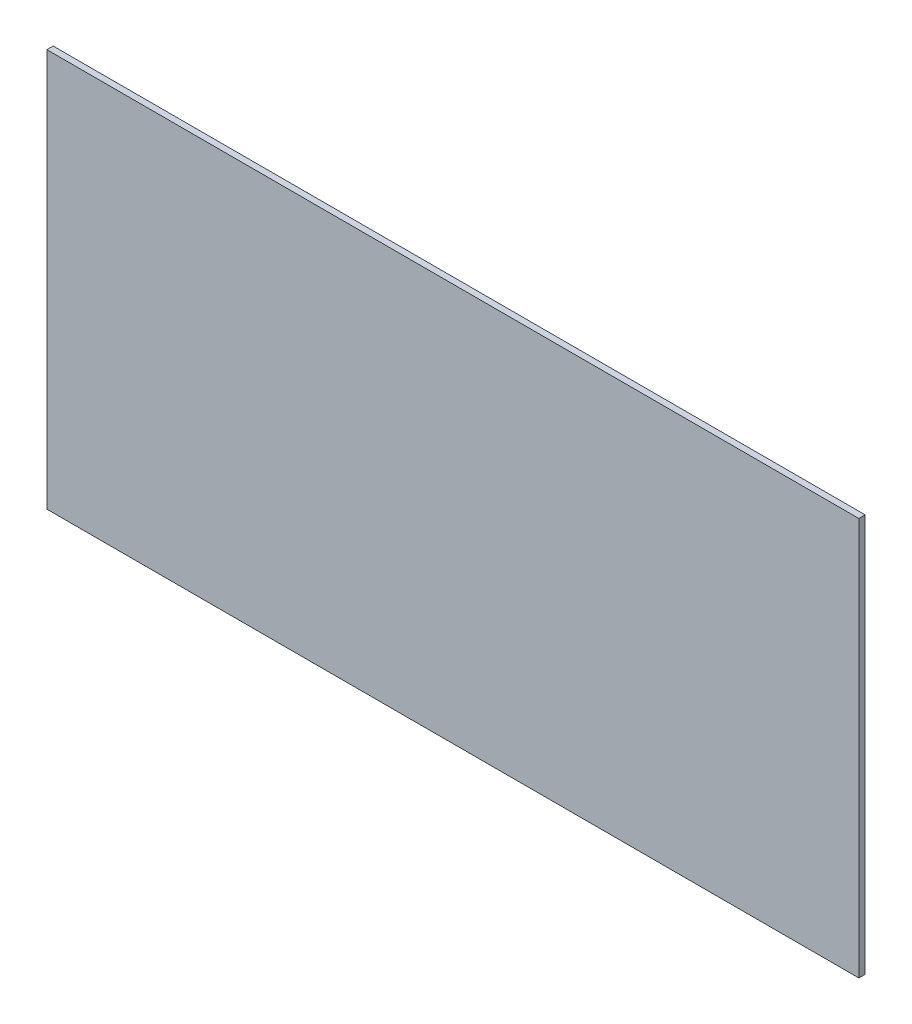
from build123d import *

# Parameters (mm, degrees)
SKETCH1_W           = 579
SKETCH1_H           = 283.75
BOSS_EXTRUDE1_DEPTH = 2.2479


with BuildPart() as part:
    # Sketch1 → Boss-Extrude1 (new body, symmetric)
    with BuildSketch(Plane.XY):
        Rectangle(SKETCH1_W, SKETCH1_H)
    extrude(amount=BOSS_EXTRUDE1_DEPTH, both=True)


solid = part.part
